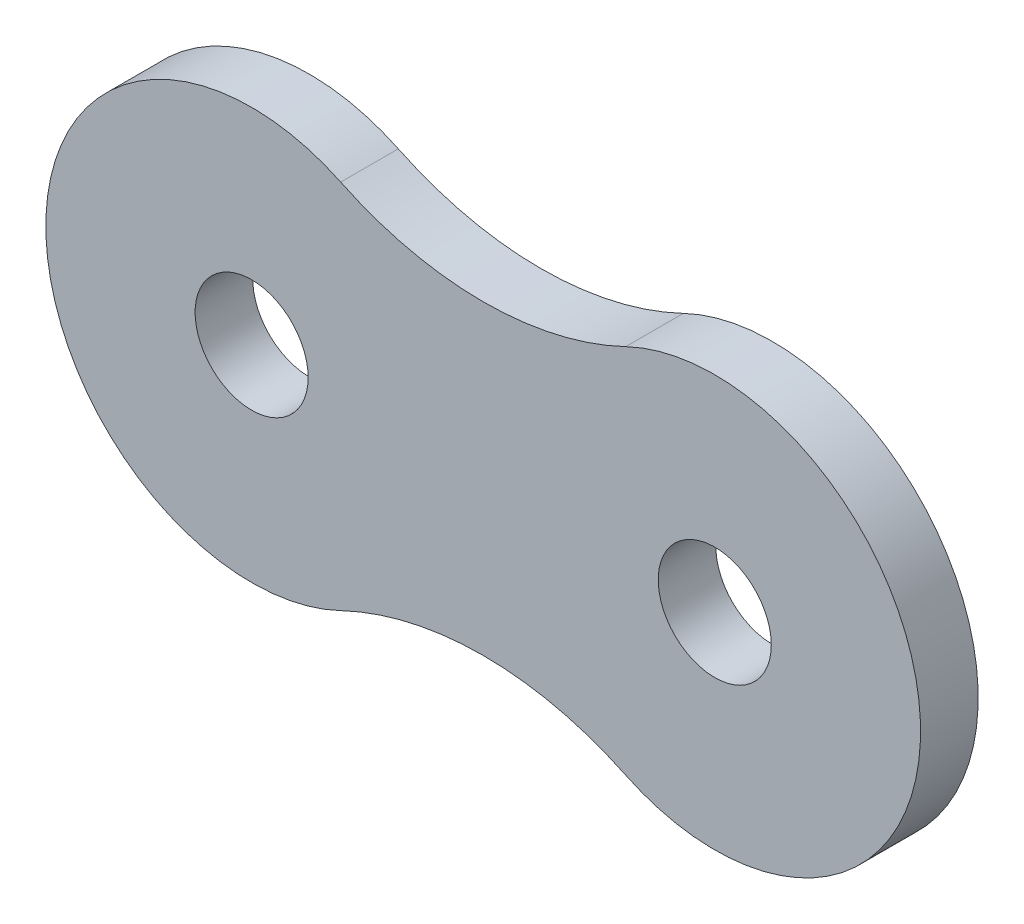
from build123d import *

# Parameters (mm, degrees)
ESQUISSE1_R      = 1.55
EXTRUSION1_DEPTH = 1.58


with BuildPart() as part:
    # Esquisse1 → Extrusion1 (new body)
    with BuildSketch(Plane.XY):
        with BuildLine():
            ThreePointArc((-2.442307752, -5.088763425), (5.644500009, 0), (-2.442307752, 5.088763425))
            ThreePointArc((-2.442307752, 5.088763425), (-6.350000027, 4.199584951), (-10.257692302, 5.088763425))
            ThreePointArc((-10.257692302, 5.088763425), (-18.344499986, 0), (-10.257692302, -5.088763425))
            ThreePointArc((-10.257692302, -5.088763425), (-6.350000027, -4.199584966), (-2.442307752, -5.088763425))
        make_face()
        Circle(ESQUISSE1_R, mode=Mode.SUBTRACT)
        with Locations((-12.7, 0)):
            Circle(ESQUISSE1_R, mode=Mode.SUBTRACT)
    extrude(amount=EXTRUSION1_DEPTH)


solid = part.part
